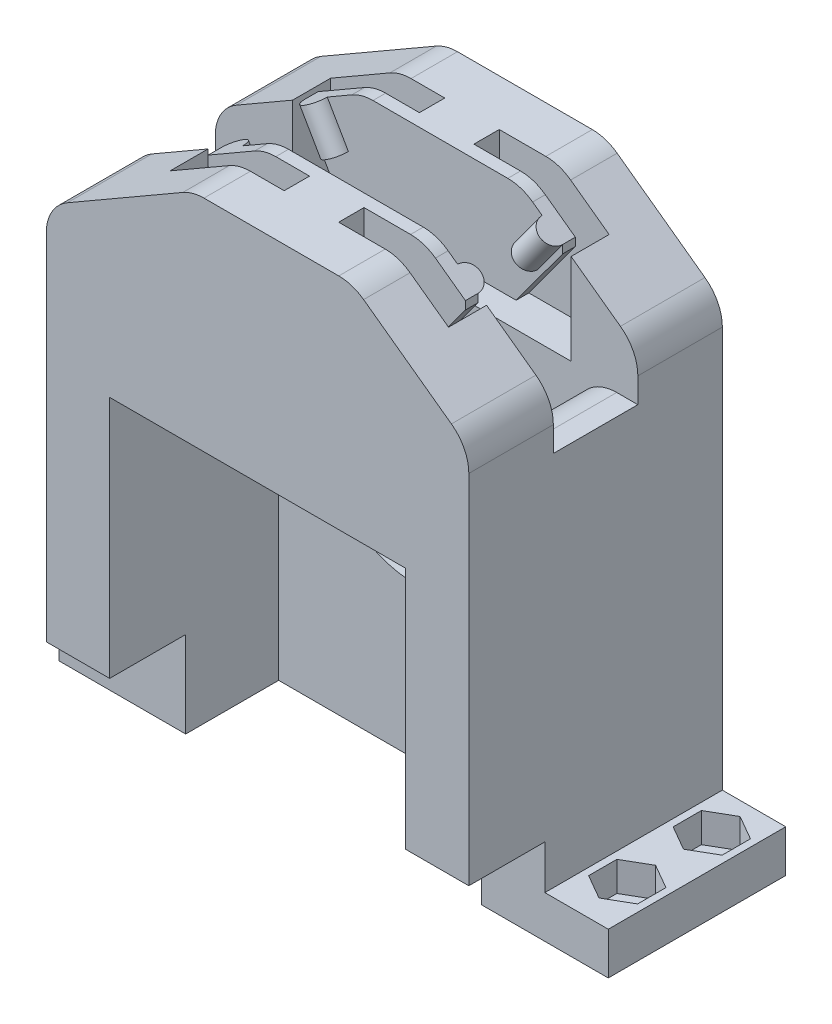
from build123d import *

# Parameters (mm, degrees)
BOSS_EXTRUDE1_DEPTH      = 30
SKETCH2_W                = 50
SKETCH2_H                = 10
CUT_EXTRUDE1_DEPTH       = 25
SKETCH4_R                = 1.5
BOSS_EXTRUDE2_DEPTH      = 5
SKETCH6_W                = 5.331604391
SKETCH6_H                = 3
SKETCH6_W_2              = 6.668395609
SKETCH6_W_3              = 12
SKETCH6_W_4              = 1.5
SKETCH6_H_2              = 4.5
CUT_EXTRUDE15_DEPTH      = 15
SKETCH7_W                = 30.5
SKETCH7_H                = 3
CUT_EXTRUDE16_DEPTH      = 13
CUT_EXTRUDE16_DEPTH_BACK = 3
SKETCH8_W                = 35
SKETCH8_H                = 39
CUT_EXTRUDE17_DEPTH      = 10
SKETCH3_W                = 35
SKETCH3_H                = 10
CUT_EXTRUDE18_DEPTH      = 40
SKETCH9_R                = 11.05
CUT_EXTRUDE19_DEPTH      = 8
FILLET5_R                = 5
FILLET6_R                = 5
FILLET7_R                = 5
FILLET8_R                = 5
FILLET9_R                = 5
FILLET10_R               = 5
SKETCH10_W               = 9
SKETCH10_H               = 10.2
CUT_EXTRUDE20_DEPTH      = 51
SKETCH11_R               = 1.5
BOSS_EXTRUDE3_DEPTH      = 5
SKETCH13_W               = 7.135367733
SKETCH13_H               = 3
SKETCH13_W_2             = 4.864632267
SKETCH13_W_3             = 12
CUT_EXTRUDE22_DEPTH      = 15
SKETCH14_W               = 21
SKETCH14_H               = 5
BOSS_EXTRUDE4_DEPTH      = 7.5
SKETCH15_W               = 21
SKETCH15_H               = 5
BOSS_EXTRUDE5_DEPTH      = 7.5
CUT_EXTRUDE23_DEPTH      = 3.5
SKETCH17_R               = 1.425
CUT_EXTRUDE24_DEPTH      = 2.5
SKETCH19_W               = 7.5
SKETCH19_H               = 10
BOSS_EXTRUDE7_DEPTH      = 9.5
FILLET14_R               = 5
FILLET18_R               = 5
FILLET19_R               = 5
FILLET20_R               = 5
FILLET21_R               = 5
FILLET22_R               = 5
FILLET23_R               = 5
FILLET24_R               = 5
SKETCH20_R               = 1.375
CUT_EXTRUDE25_DEPTH      = 10
SKETCH21_R               = 5.5
CUT_EXTRUDE26_DEPTH      = 10
CUT_EXTRUDE27_DEPTH      = 14
CUT_EXTRUDE27_DEPTH_BACK = 3


with BuildPart() as part:
    # Sketch1 → Boss-Extrude1 (new body)
    with BuildSketch(Plane.XY):
        Polygon((19.499094274, 17.872269618), (0.583421555, 17.872269618), (-16.737086521, 7.872269618), (-16.737086521, -47.127730382), (33.262913479, -47.127730382), (33.262913479, 7.872269618), align=None)
    extrude(amount=BOSS_EXTRUDE1_DEPTH)

    # Sketch2 → Cut-Extrude1 (cut)
    with BuildSketch(Plane(origin=(0, 17.872269618, 0), x_dir=(1, 0, 0), z_dir=(0, 1, 0))):
        with Locations((8.262913479, -15)):
            Rectangle(SKETCH2_W, SKETCH2_H)
    extrude(amount=-CUT_EXTRUDE1_DEPTH, mode=Mode.SUBTRACT)

    # Sketch4 → Boss-Extrude2 (add)
    with BuildSketch(Plane(origin=(-7.593064367, 13.151573269, 0), x_dir=(0, 0, 1), z_dir=(-0.5, 0.866025404, 0))):
        with Locations((10, 3.241392696)):
            Circle(SKETCH4_R)
        with Locations((20, 3.241392696)):
            Circle(SKETCH4_R)
    extrude(amount=-BOSS_EXTRUDE2_DEPTH)

    # Sketch6 → Cut-Extrude15 (cut)
    with BuildSketch(Plane(origin=(0, 17.872269618, 0), x_dir=(1, 0, 0), z_dir=(0, 1, 0))):
        with Locations((3.249223751, -7)):
            Rectangle(SKETCH6_W, SKETCH6_H)
        with Locations((-2.75077625, -7)):
            Rectangle(SKETCH6_W_2, SKETCH6_H)
        with Locations((-0.084974054, -23)):
            Rectangle(SKETCH6_W_3, SKETCH6_H)
        Polygon((-6.084974054, -24.5), (-6.084974054, -21.5), (-6.084974054, -20), (-7.584974054, -20), (-7.584974054, -24.5), align=None)
        with Locations((-6.834974054, -7.75)):
            Rectangle(SKETCH6_W_4, SKETCH6_H_2)
    extrude(amount=-CUT_EXTRUDE15_DEPTH, mode=Mode.SUBTRACT)

    # Sketch7 → Cut-Extrude16 (cut, two sides)
    with BuildSketch(Plane.XY.offset(10)) as cut_extrude16_sk:
        with Locations((9.165025946, 4.372269618)):
            Rectangle(SKETCH7_W, SKETCH7_H)
    extrude(amount=CUT_EXTRUDE16_DEPTH, mode=Mode.SUBTRACT)
    extrude(cut_extrude16_sk.sketch, amount=-CUT_EXTRUDE16_DEPTH_BACK, mode=Mode.SUBTRACT)

    # Sketch8 → Cut-Extrude17 (cut)
    with BuildSketch(Plane.XY.offset(30)):
        with Locations((8.262913479, -27.627730382)):
            Rectangle(SKETCH8_W, SKETCH8_H)
    extrude(amount=-CUT_EXTRUDE17_DEPTH, mode=Mode.SUBTRACT)

    # Sketch3 → Cut-Extrude18 (cut)
    with BuildSketch(Plane.XZ.offset(47.127730382)):
        with Locations((8.262913479, 15)):
            Rectangle(SKETCH3_W, SKETCH3_H)
    extrude(amount=-CUT_EXTRUDE18_DEPTH, mode=Mode.SUBTRACT)

    # Sketch9 → Cut-Extrude19 (cut)
    with BuildSketch(Plane.XY.offset(10)):
        with Locations((6.889118081, -18.127730382)):
            Circle(SKETCH9_R)
    extrude(amount=-CUT_EXTRUDE19_DEPTH, mode=Mode.SUBTRACT)

    # Fillet5
    fillet5_edges = [part.edges().sort_by_distance(p)[0] for p in [
        (-16.737086521, 7.872269618, 5),
    ]]
    fillet(fillet5_edges, radius=FILLET5_R)

    # Fillet6
    fillet6_edges = [part.edges().sort_by_distance(p)[0] for p in [
        (-16.737086521, 7.872269618, 25),
    ]]
    fillet(fillet6_edges, radius=FILLET6_R)

    # Fillet7
    fillet7_edges = [part.edges().sort_by_distance(p)[0] for p in [
        (0.583421555, 17.872269618, 2.75),
    ]]
    fillet(fillet7_edges, radius=FILLET7_R)

    # Fillet8
    fillet8_edges = [part.edges().sort_by_distance(p)[0] for p in [
        (0.583421555, 17.872269618, 9.25),
    ]]
    fillet(fillet8_edges, radius=FILLET8_R)

    # Fillet9
    fillet9_edges = [part.edges().sort_by_distance(p)[0] for p in [
        (0.583421555, 17.872269618, 20.75),
    ]]
    fillet(fillet9_edges, radius=FILLET9_R)

    # Fillet10
    fillet10_edges = [part.edges().sort_by_distance(p)[0] for p in [
        (0.583421555, 17.872269618, 27.25),
    ]]
    fillet(fillet10_edges, radius=FILLET10_R)

    # Sketch10 → Cut-Extrude20 (cut, through all)
    with BuildSketch(Plane(origin=(33.262913479, 0, 0), x_dir=(0, 0, -1), z_dir=(1, 0, 0))):
        with Locations((-25.5, -42.027730382)):
            Rectangle(SKETCH10_W, SKETCH10_H)
    extrude(amount=-CUT_EXTRUDE20_DEPTH, mode=Mode.SUBTRACT)

    # Sketch11 → Boss-Extrude3 (add)
    with BuildSketch(Plane(origin=(15.235540625, 20.969922665, 0), x_dir=(0, 0, -1), z_dir=(0.587785252, 0.809016994, 0))):
        with Locations((-20, -9.783058304)):
            Circle(SKETCH11_R)
        with Locations((-10, -9.783058304)):
            Circle(SKETCH11_R)
    extrude(amount=-BOSS_EXTRUDE3_DEPTH)

    # Sketch13 → Cut-Extrude22 (cut)
    with BuildSketch(Plane(origin=(0, 17.872269618, 0), x_dir=(1, 0, 0), z_dir=(0, 1, 0))):
        with Locations((15.931410407, -23)):
            Rectangle(SKETCH13_W, SKETCH13_H)
        with Locations((21.931410408, -23)):
            Rectangle(SKETCH13_W_2, SKETCH13_H)
        Polygon((24.363726541, -21.5), (24.363726541, -24.5), (25.363726541, -24.5), (25.363726541, -14.929315396), (24.363726541, -14.929315396), align=None)
        Polygon((24.363726541, -5.5), (24.363726541, -8.5), (24.363726541, -11.278829463), (25.363726541, -11.278829463), (25.363726541, -5.5), align=None)
        with Locations((18.363726541, -7)):
            Rectangle(SKETCH13_W_3, SKETCH13_H)
    extrude(amount=-CUT_EXTRUDE22_DEPTH, mode=Mode.SUBTRACT)

    # Sketch14 → Boss-Extrude4 (add)
    with BuildSketch(Plane.ZY.offset(16.737086521)):
        with Locations((10.5, -44.627730382)):
            Rectangle(SKETCH14_W, SKETCH14_H)
    extrude(amount=BOSS_EXTRUDE4_DEPTH)

    # Sketch15 → Boss-Extrude5 (add)
    with BuildSketch(Plane(origin=(33.262913479, 0, 0), x_dir=(0, 0, -1), z_dir=(1, 0, 0))):
        with Locations((-10.5, -44.627730382)):
            Rectangle(SKETCH15_W, SKETCH15_H)
    extrude(amount=BOSS_EXTRUDE5_DEPTH)

    # Sketch16 → Cut-Extrude23 (cut)
    with BuildSketch(Plane(origin=(0, -42.127730382, 0), x_dir=(1, 0, 0), z_dir=(0, 1, 0))):
        Polygon((37.012913479, -11.651368439), (34.112913479, -13.325684219), (34.112913479, -16.674315781), (37.012913479, -18.348631561), (39.912913479, -16.674315781), (39.912913479, -13.325684219), align=None)
        Polygon((37.012913479, -1.651368439), (34.112913479, -3.325684219), (34.112913479, -6.674315781), (37.012913479, -8.348631561), (39.912913479, -6.674315781), (39.912913479, -3.325684219), align=None)
    extrude(amount=-CUT_EXTRUDE23_DEPTH, mode=Mode.SUBTRACT)

    # Sketch17 → Cut-Extrude24 (cut, through all)
    with BuildSketch(Plane(origin=(0, -45.627730382, 0), x_dir=(1, 0, 0), z_dir=(0, 1, 0))):
        with Locations((37.012913479, -15)):
            Circle(SKETCH17_R)
        with Locations((37.012913479, -5)):
            Circle(SKETCH17_R)
    extrude(amount=-CUT_EXTRUDE24_DEPTH, mode=Mode.SUBTRACT)

    # Sketch19 → Boss-Extrude7 (add)
    with BuildSketch(Plane(origin=(0, -7.127730382, 0), x_dir=(1, 0, 0), z_dir=(0, 1, 0))):
        with Locations((-12.987086521, -15)):
            Rectangle(SKETCH19_W, SKETCH19_H)
        with Locations((29.512913479, -15)):
            Rectangle(SKETCH19_W, SKETCH19_H)
    extrude(amount=BOSS_EXTRUDE7_DEPTH)

    # Fillet14
    fillet14_edges = [part.edges().sort_by_distance(p)[0] for p in [
        (-9.237086521, 2.372269618, 15),
    ]]
    fillet(fillet14_edges, radius=FILLET14_R)

    # Fillet18
    fillet18_edges = [part.edges().sort_by_distance(p)[0] for p in [
        (25.762913479, 2.372269618, 15),
    ]]
    fillet(fillet18_edges, radius=FILLET18_R)

    # Fillet19
    fillet19_edges = [part.edges().sort_by_distance(p)[0] for p in [
        (33.262913479, 7.872269618, 5),
    ]]
    fillet(fillet19_edges, radius=FILLET19_R)

    # Fillet20
    fillet20_edges = [part.edges().sort_by_distance(p)[0] for p in [
        (33.262913479, 7.872269618, 25),
    ]]
    fillet(fillet20_edges, radius=FILLET20_R)

    # Fillet21
    fillet21_edges = [part.edges().sort_by_distance(p)[0] for p in [
        (19.499094274, 17.872269618, 2.75),
    ]]
    fillet(fillet21_edges, radius=FILLET21_R)

    # Fillet22
    fillet22_edges = [part.edges().sort_by_distance(p)[0] for p in [
        (19.499094274, 17.872269618, 9.25),
    ]]
    fillet(fillet22_edges, radius=FILLET22_R)

    # Fillet23
    fillet23_edges = [part.edges().sort_by_distance(p)[0] for p in [
        (19.499094274, 17.872269618, 27.25),
    ]]
    fillet(fillet23_edges, radius=FILLET23_R)

    # Fillet24
    fillet24_edges = [part.edges().sort_by_distance(p)[0] for p in [
        (19.499094274, 17.872269618, 20.75),
    ]]
    fillet(fillet24_edges, radius=FILLET24_R)

    # Sketch20 → Cut-Extrude25 (cut)
    with BuildSketch(Plane(origin=(0, -42.127730382, 0), x_dir=(1, 0, 0), z_dir=(0, 1, 0))):
        with Locations((-20.537086521, -11)):
            Circle(SKETCH20_R)
    extrude(amount=-CUT_EXTRUDE25_DEPTH, mode=Mode.SUBTRACT)

    # Sketch21 → Cut-Extrude26 (cut)
    with BuildSketch(Plane.XY.offset(2)):
        with Locations((6.889118081, -18.127730382)):
            Circle(SKETCH21_R)
    extrude(amount=-CUT_EXTRUDE26_DEPTH, mode=Mode.SUBTRACT)

    # Sketch22 → Cut-Extrude27 (cut, two sides)
    with BuildSketch(Plane.XY.offset(10)) as cut_extrude27_sk:
        Polygon((-2.084974054, 5.872269618), (-6.084974054, 12.872269618), (-6.084974054, 5.872269618), align=None)
        Polygon((24.363726541, 13.372269618), (18.863726541, 5.872269618), (24.363726541, 5.872269618), align=None)
    extrude(amount=CUT_EXTRUDE27_DEPTH, mode=Mode.SUBTRACT)
    extrude(cut_extrude27_sk.sketch, amount=-CUT_EXTRUDE27_DEPTH_BACK, mode=Mode.SUBTRACT)


solid = part.part
